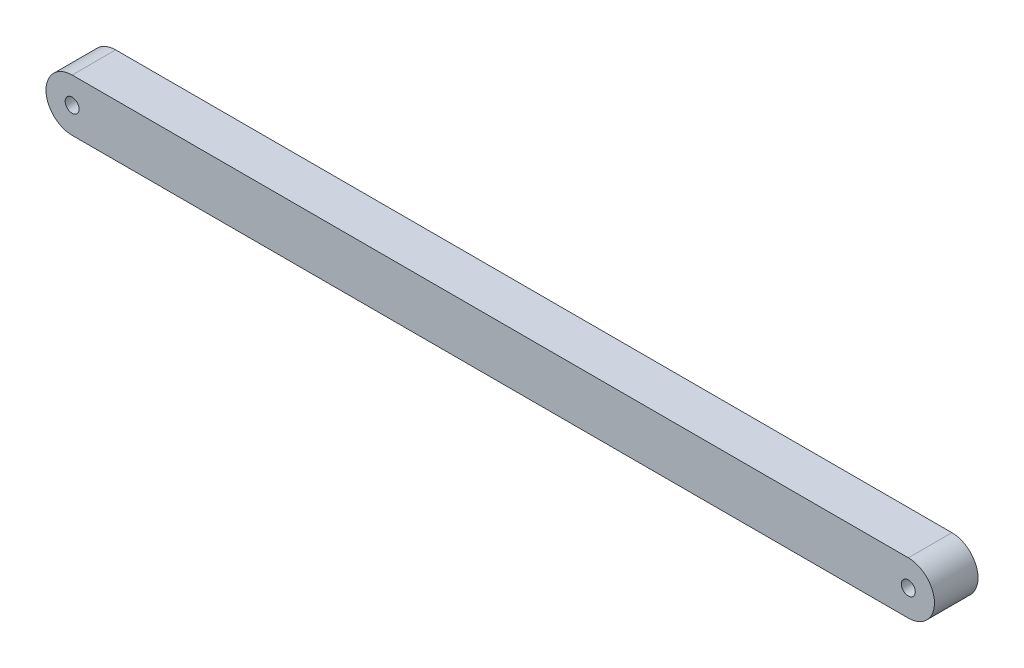
from build123d import *

# Parameters (mm, degrees)
SKETCH1_R           = 1.6
BOSS_EXTRUDE1_DEPTH = 10
SKETCH2_R           = 1.6
CUT_EXTRUDE1_DEPTH  = 10
SKETCH3_R           = 1.6
BOSS_EXTRUDE2_DEPTH = 10


with BuildPart() as part:
    # Sketch1 → Boss-Extrude1 (new body)
    with BuildSketch(Plane.XY):
        with BuildLine():
            Line((0, 6), (196, 6))
            ThreePointArc((196, 6), (202, 0), (196, -6))
            Line((196, -6), (0, -6))
            ThreePointArc((0, -6), (-6, 0), (0, 6))
        make_face()
        Circle(SKETCH1_R, mode=Mode.SUBTRACT)
        with Locations((196, 0)):
            Circle(SKETCH1_R, mode=Mode.SUBTRACT)
    extrude(amount=BOSS_EXTRUDE1_DEPTH)

    # Sketch2 → Cut-Extrude1 (cut)
    with BuildSketch(Plane.XY.offset(10)):
        with Locations((192, 0)):
            Circle(SKETCH2_R)
        with BuildLine():
            Line((196, 6), (192, 6))
            ThreePointArc((192, 6), (198, 0), (192, -6))
            Line((192, -6), (196, -6))
            ThreePointArc((196, -6), (202, 0), (196, 6))
        make_face()
    extrude(amount=-CUT_EXTRUDE1_DEPTH, mode=Mode.SUBTRACT)

    # Sketch3 → Boss-Extrude2 (add)
    with BuildSketch(Plane.XY.offset(10)):
        with Locations((196, 0)):
            Circle(SKETCH3_R)
    extrude(amount=-BOSS_EXTRUDE2_DEPTH)


solid = part.part
